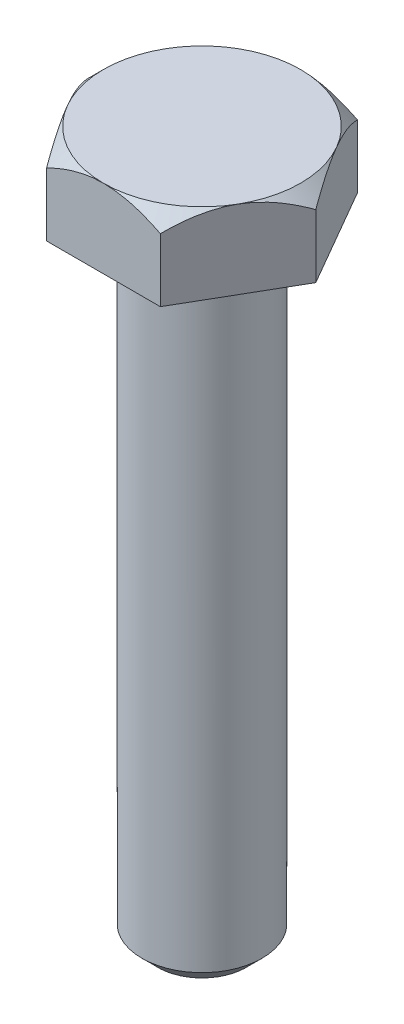
from build123d import *

# Parameters (mm, degrees)
EXTRUDE_1_DEPTH     = 5
SKETCH_8_OUTSIDE_W  = 22.464
SKETCH_8_OUTSIDE_H  = 20.522
SKETCH_8_OUTSIDE_R  = 6.278684177
CUT_EXTRUDE_1_DEPTH = 1
CUT_EXTRUDE_1_DRAFT = -45
SKETCH_9_R          = 3.825
BOLT_LENGTH_DEPTH   = 40
FILLET_1_R          = 1
CHAMFER_1_SIZE      = 1


with BuildPart() as part:
    # Эскиз6 → Бобышка-Вытянуть1 (new body)
    with BuildSketch(Plane(origin=(0, 0, 0), x_dir=(1, 0, 0), z_dir=(0, 1, 0))):
        Polygon((7.25, 0), (3.625, 6.278684177), (-3.625, 6.278684177), (-7.25, 0), (-3.625, -6.278684177), (3.625, -6.278684177), align=None)
    extrude(amount=EXTRUDE_1_DEPTH)


with BuildPart() as cut_extrude_1_tool:
    # Эскиз8 outside → Вырез-Вытянуть1 (with draft: the straight prism first)
    with BuildSketch(Plane(origin=(0, 5, 0), x_dir=(1, 0, 0), z_dir=(0, 1, 0))):
        Rectangle(SKETCH_8_OUTSIDE_W, SKETCH_8_OUTSIDE_H)
        Circle(SKETCH_8_OUTSIDE_R, mode=Mode.SUBTRACT)
    extrude(amount=-CUT_EXTRUDE_1_DEPTH)
    # Вырез-Вытянуть1: the draft: its side faces are tilted about the plane it starts from
    cut_extrude_1_sides = [cut_extrude_1_tool.faces().sort_by_distance(p)[0] for p in [
        (0, 4.5, 10.261),
        (11.232, 4.5, 0),
        (0, 4.5, -10.261),
        (-11.232, 4.5, 0),
        (-6.278684177, 4.5, 0),
    ]]
    draft(cut_extrude_1_sides, Plane(origin=(0, 5, 0), x_dir=(1, 0, 0), z_dir=(0, 1, 0)), CUT_EXTRUDE_1_DRAFT)


with BuildPart() as part_1:
    add(part.part)

    # Вырез-Вытянуть1: cut by cut_extrude_1_tool
    add(cut_extrude_1_tool.part, mode=Mode.SUBTRACT)

    # Эскиз9 → bolt length (add)
    with BuildSketch(Plane.XZ):
        with Locations(Location((0, 0, 0), (0, 0, 90))):  # turned: the seam where the file's is
            Circle(SKETCH_9_R)
    extrude(amount=BOLT_LENGTH_DEPTH)

    # Скругление1
    fillet_1_edges = [part_1.edges().sort_by_distance(p)[0] for p in [
        (0, 0, -3.825),
    ]]
    fillet(fillet_1_edges, radius=FILLET_1_R)

    # Фаска1
    chamfer_1_edges = [part_1.edges().sort_by_distance(p)[0] for p in [
        (0, -40, -3.825),
    ]]
    chamfer(chamfer_1_edges, length=CHAMFER_1_SIZE)


solid = part_1.part
